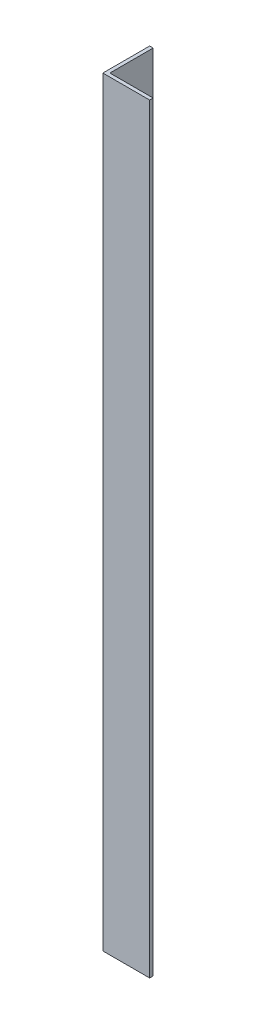
from build123d import *

# Parameters (mm, degrees)
EXTRUDE_1_DEPTH = 650


with BuildPart() as part:
    # Эскиз1 → Вытянуть-Тонкостенный1 (new body)
    with BuildSketch(Plane(origin=(0, 0, 0), x_dir=(1, 0, 0), z_dir=(0, 1, 0))):
        Polygon((0, 40), (0, 0), (40, 0), (40, 3), (3, 3), (3, 40), align=None)
    extrude(amount=EXTRUDE_1_DEPTH)


solid = part.part
